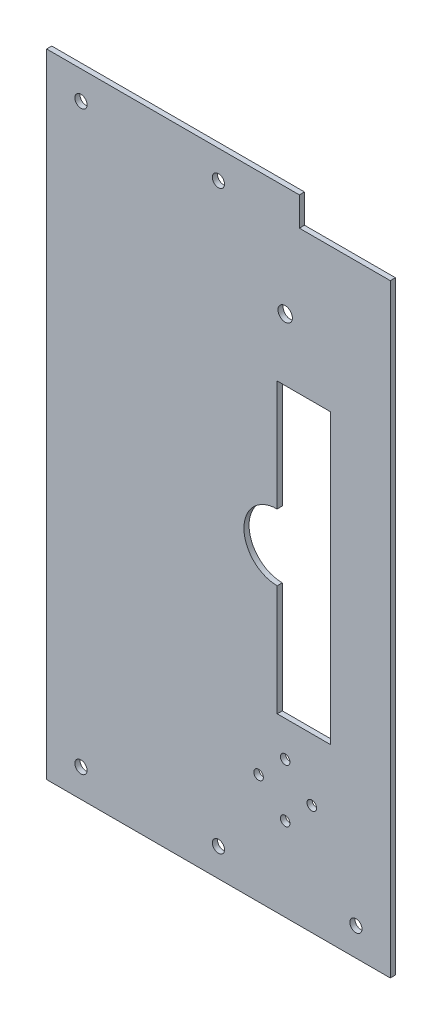
from build123d import *

# Parameters (mm, degrees)
SKETCH1_W            = 155
SKETCH1_H            = 285.39
BOSS_EXTRUDE1_DEPTH  = 2.305
M5_CLEARANCE_HOLE1_D = 5.5
SKETCH4_R            = 2.15
SKETCH4_R_2          = 3.25
CUT_EXTRUDE1_DEPTH   = 3.305
SKETCH5_W            = 41
SKETCH5_H            = 13
CUT_EXTRUDE2_DEPTH   = 10
CUT_EXTRUDE3_DEPTH   = 3.305


with BuildPart() as part:
    # Sketch1 → Boss-Extrude1 (new body)
    with BuildSketch(Plane.XY):
        Rectangle(SKETCH1_W, SKETCH1_H)
    extrude(amount=BOSS_EXTRUDE1_DEPTH)

    # M5 Clearance Hole1 (through all)
    with Locations(Plane.XY.offset(2.305)):
        with Locations((-62, 129.995), (0, 129.995), (-62, -129.995), (0, -129.995), (62, -129.995)):
            Hole(M5_CLEARANCE_HOLE1_D / 2)

    # Sketch4 → Cut-Extrude1 (cut, through all)
    with BuildSketch(Plane.XY.offset(2.305)):
        with Locations((30.1, -81)):
            Circle(SKETCH4_R)
        with Locations((42.1, -93)):
            Circle(SKETCH4_R)
        with Locations((30.1, -105)):
            Circle(SKETCH4_R)
        with Locations((18.1, -93)):
            Circle(SKETCH4_R)
        with Locations((30.1, 93)):
            Circle(SKETCH4_R_2)
    extrude(amount=-CUT_EXTRUDE1_DEPTH, mode=Mode.SUBTRACT)

    # Sketch5 → Cut-Extrude2 (cut)
    with BuildSketch(Plane.XY.offset(2.305)):
        with Locations((57, 136.195)):
            Rectangle(SKETCH5_W, SKETCH5_H)
    extrude(amount=-CUT_EXTRUDE2_DEPTH, mode=Mode.SUBTRACT)

    # Sketch6 → Cut-Extrude3 (cut, through all)
    with BuildSketch(Plane.XY.offset(2.305)):
        with BuildLine():
            Line((26.5, 65), (50.5, 65))
            Line((50.5, 65), (50.5, -65))
            Line((50.5, -65), (26.5, -65))
            Line((26.5, -65), (26.5, -15))
            ThreePointArc((26.5, -15), (11.5, 0), (26.5, 15))
            Line((26.5, 15), (26.5, 65))
        make_face()
    extrude(amount=-CUT_EXTRUDE3_DEPTH, mode=Mode.SUBTRACT)


solid = part.part
